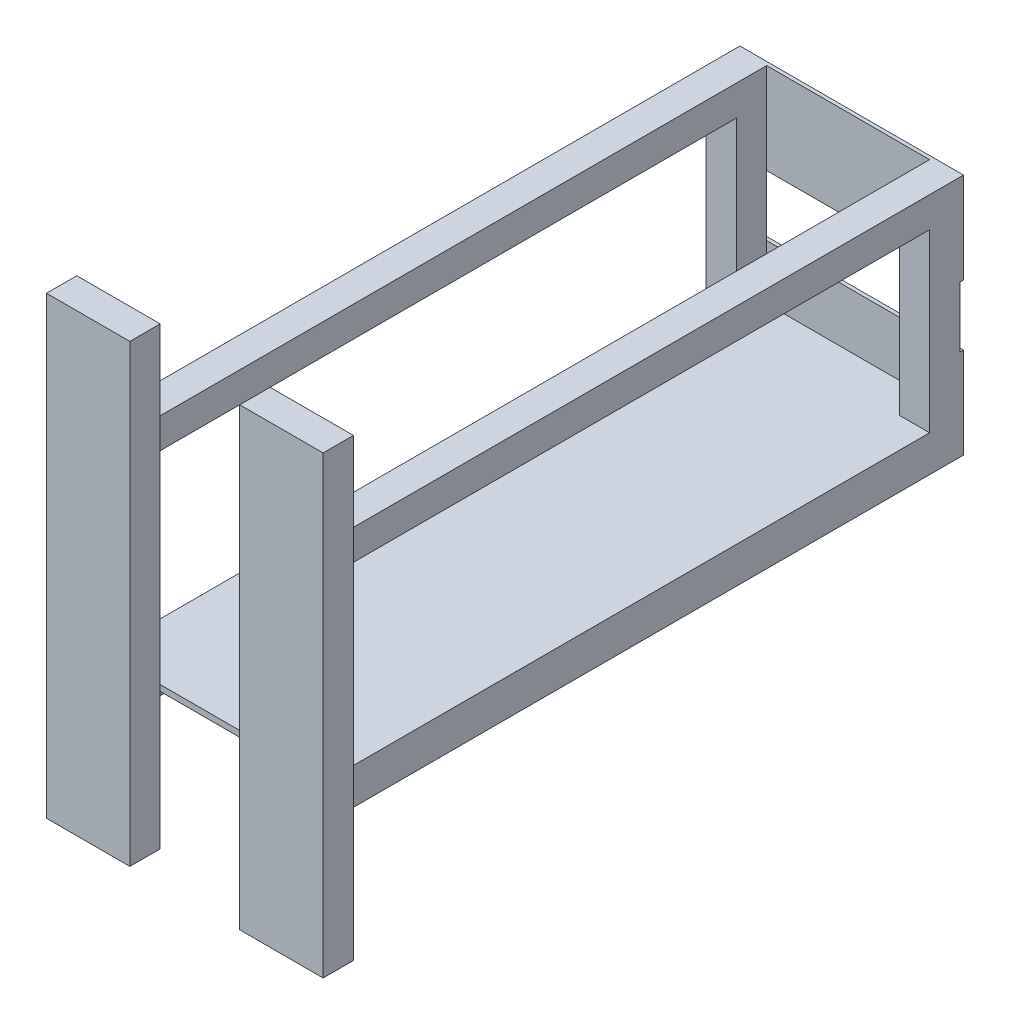
from build123d import *

# Parameters (mm, degrees)
SKETCH1_W           = 374.65
SKETCH1_H           = 406.4
BOSS_EXTRUDE1_DEPTH = 6
SKETCH1_5_W         = 50.8
SKETCH1_5_H         = 50.8
BOSS_EXTRUDE2_DEPTH = 1066.8
SKETCH3_W           = 139.7
SKETCH3_H           = 762
BOSS_EXTRUDE4_DEPTH = 50.8
SKETCH4_W           = 374.65
SKETCH4_H           = 1060.8
BOSS_EXTRUDE5_DEPTH = 10
SKETCH5_W           = 374.65
SKETCH5_H           = 101.6
CUT_EXTRUDE1_DEPTH  = 10
BOSS_EXTRUDE7_REACH = 1309.36
SKETCH6_W           = 50.8
SKETCH6_H           = 50.8


with BuildPart() as part:
    # Sketch1 → Boss-Extrude1 (new body)
    with BuildSketch(Plane.XY):
        with Locations((187.325, 203.2)):
            Rectangle(SKETCH1_W, SKETCH1_H)
    extrude(amount=BOSS_EXTRUDE1_DEPTH)

    # Sketch1_5 → Boss-Extrude2 (add)
    with BuildSketch(Plane.XY):
        with Locations((25.4, 381)):
            Rectangle(SKETCH1_5_W, SKETCH1_5_H)
        with Locations((25.4, 25.4)):
            Rectangle(SKETCH1_5_W, SKETCH1_5_H)
        with Locations((349.25, 25.4)):
            Rectangle(SKETCH1_5_W, SKETCH1_5_H)
        with Locations((349.25, 381)):
            Rectangle(SKETCH1_5_W, SKETCH1_5_H)
    extrude(amount=BOSS_EXTRUDE2_DEPTH)

    # Sketch3 → Boss-Extrude4 (add)
    with BuildSketch(Plane.XY.offset(1066.8)):
        with Locations((25.4, 203.2)):
            Rectangle(SKETCH3_W, SKETCH3_H)
        with Locations((349.25, 203.2)):
            Rectangle(SKETCH3_W, SKETCH3_H)
    extrude(amount=BOSS_EXTRUDE4_DEPTH)

    # Sketch4 → Boss-Extrude5 (add)
    with BuildSketch(Plane(origin=(0, 50.8, 0), x_dir=(1, 0, 0), z_dir=(0, 1, 0))):
        with Locations((187.325, -536.4)):
            Rectangle(SKETCH4_W, SKETCH4_H)
    extrude(amount=BOSS_EXTRUDE5_DEPTH)

    # Sketch5 → Cut-Extrude1 (cut)
    with BuildSketch(Plane(origin=(0, 0, 0), x_dir=(-1, 0, 0), z_dir=(0, 0, -1))):
        with Locations((-187.325, 203.2)):
            Rectangle(SKETCH5_W, SKETCH5_H)
    extrude(amount=-CUT_EXTRUDE1_DEPTH, mode=Mode.SUBTRACT)

    # Sketch6 → Boss-Extrude7 (add, up to next)
    with BuildSketch(Plane.XZ.offset(-355.6), mode=Mode.PRIVATE) as boss_extrude7_sk1:
        with Locations((25.4, 31.4)):
            Rectangle(SKETCH6_W, SKETCH6_H)
    boss_extrude7_tool1 = extrude(boss_extrude7_sk1.sketch, amount=BOSS_EXTRUDE7_REACH, mode=Mode.PRIVATE) - part.part
    # Sketch6 → Boss-Extrude7 (add, up to next)
    with BuildSketch(Plane.XZ.offset(-355.6), mode=Mode.PRIVATE) as boss_extrude7_sk2:
        with Locations((349.25, 31.4)):
            Rectangle(SKETCH6_W, SKETCH6_H)
    boss_extrude7_tool2 = extrude(boss_extrude7_sk2.sketch, amount=BOSS_EXTRUDE7_REACH, mode=Mode.PRIVATE) - part.part
    add(boss_extrude7_tool1.solids().sort_by_distance((25.4, 355.6, 31.4))[0])
    add(boss_extrude7_tool2.solids().sort_by_distance((349.25, 355.6, 31.4))[0])


solid = part.part
